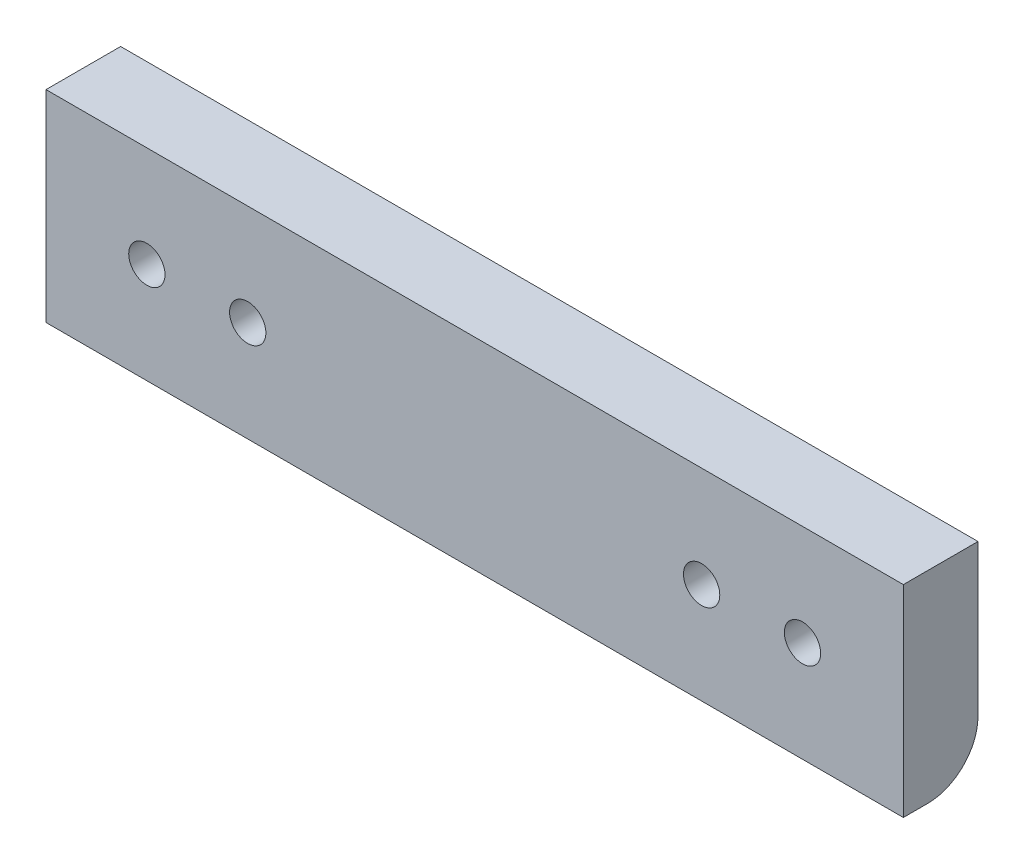
from build123d import *

# Parameters (mm, degrees)
SKETCH1_W           = 85
SKETCH1_H           = 20
SKETCH1_R           = 1.8
BOSS_EXTRUDE1_DEPTH = 7.4
CUT_EXTRUDE1_DEPTH  = 4.4
FILLET1_R           = 5


with BuildPart() as part:
    # Sketch1 → Boss-Extrude1 (new body)
    with BuildSketch(Plane.XY):
        Rectangle(SKETCH1_W, SKETCH1_H)
        with Locations((-32.5, 0)):
            Circle(SKETCH1_R, mode=Mode.SUBTRACT)
        with Locations((-22.5, 0)):
            Circle(SKETCH1_R, mode=Mode.SUBTRACT)
        with Locations((32.5, 0)):
            Circle(SKETCH1_R, mode=Mode.SUBTRACT)
        with Locations((22.5, 0)):
            Circle(SKETCH1_R, mode=Mode.SUBTRACT)
    extrude(amount=BOSS_EXTRUDE1_DEPTH)

    # Sketch2 → Cut-Extrude1 (cut)
    with BuildSketch(Plane(origin=(0, 0, 0), x_dir=(-1, 0, 0), z_dir=(0, 0, -1))):
        Polygon((20.652479139, -3.2), (18.804958277, 0), (20.652479139, 3.2), (24.347520861, 3.2), (26.195041723, 0), (24.347520861, -3.2), align=None)
        Polygon((36.195041723, 0), (34.347520861, 3.2), (30.652479139, 3.2), (28.804958277, 0), (30.652479139, -3.2), (34.347520861, -3.2), align=None)
        Polygon((-18.804958277, 0), (-20.652479139, 3.2), (-24.347520861, 3.2), (-26.195041723, 0), (-24.347520861, -3.2), (-20.652479139, -3.2), align=None)
        Polygon((-34.347520861, -3.2), (-36.195041723, 0), (-34.347520861, 3.2), (-30.652479139, 3.2), (-28.804958277, 0), (-30.652479139, -3.2), align=None)
    extrude(amount=-CUT_EXTRUDE1_DEPTH, mode=Mode.SUBTRACT)

    # Fillet1
    fillet1_edges = [part.edges().sort_by_distance(p)[0] for p in [
        (0, -10, 0),
    ]]
    fillet(fillet1_edges, radius=FILLET1_R)


solid = part.part
